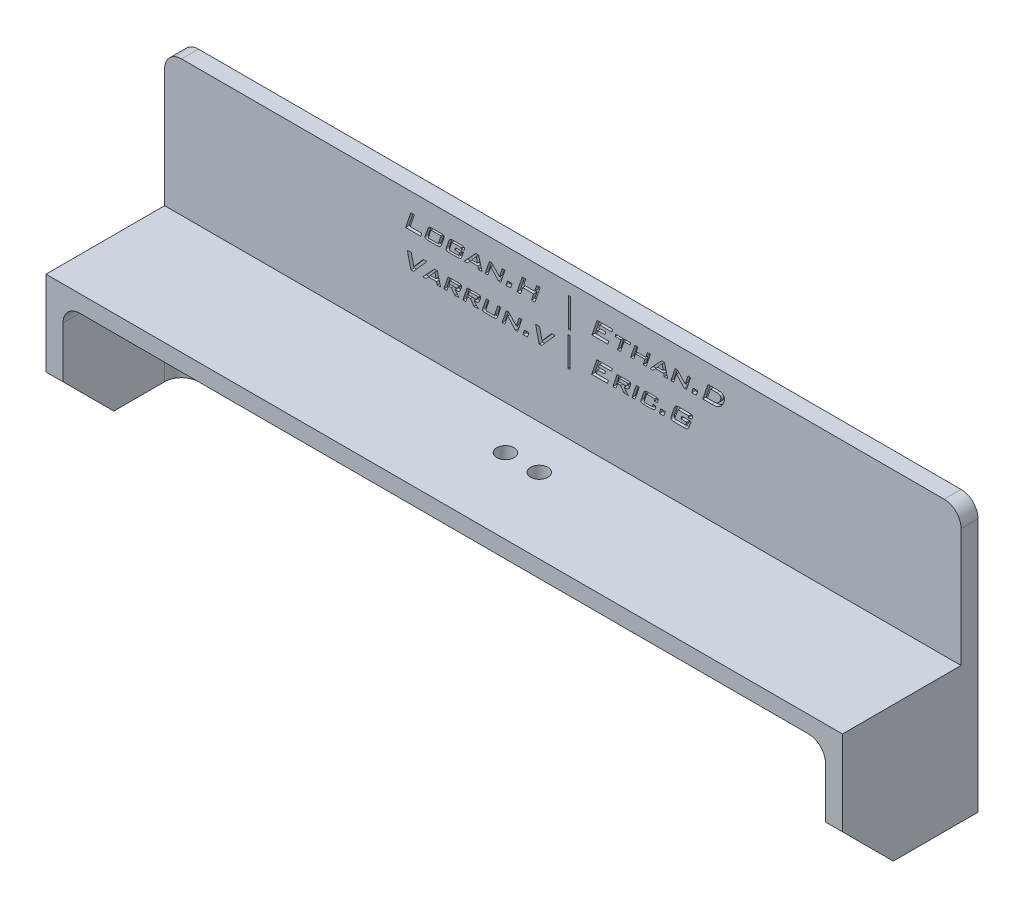
from build123d import *

# Parameters (mm, degrees)
SKETCH1_W                  = 235
SKETCH1_H                  = 40
BOSS_EXTRUDE1_DEPTH        = 5
BOSS_EXTRUDE2_DEPTH        = 35
M4_CLEARANCE_HOLE1_D       = 4.5
F_5_1_5_1_DIAMETER_HOLE1_D = 5.1
SKETCH7_W                  = 235
SKETCH7_H                  = 5
BOSS_EXTRUDE3_DEPTH        = 40
FILLET1_R                  = 5
FILLET2_R                  = 5
CHAMFER3_SIZE              = 15
SKETCH9_W                  = 0.642857143
SKETCH9_H                  = 8.678571428
CUT_EXTRUDE1_DEPTH         = 1


with BuildPart() as part:
    # Sketch1 → Boss-Extrude1 (new body)
    with BuildSketch(Plane(origin=(0, 0, 0), x_dir=(1, 0, 0), z_dir=(0, 1, 0))):
        with Locations((117.5, -20)):
            Rectangle(SKETCH1_W, SKETCH1_H)
    extrude(amount=BOSS_EXTRUDE1_DEPTH)

    # Sketch2 → Boss-Extrude2 (add)
    with BuildSketch(Plane.XZ):
        Polygon((5, 5), (230, 5), (230, 40), (235, 40), (235, 5), (235, 0), (0, 0), (0, 5), (0, 40), (5, 40), align=None)
    extrude(amount=BOSS_EXTRUDE2_DEPTH)

    # M4 Clearance Hole1 (through all)
    with Locations(Plane.XY.offset(5)):
        with Locations((117.5, -15), (55, -15), (180, -15)):
            Hole(M4_CLEARANCE_HOLE1_D / 2)

    # Ø5.1 (5.1) Diameter Hole1 (through all)
    with Locations(Plane.XZ):
        with Locations((113.391, 17.85), (123.391, 17.85)):
            Hole(F_5_1_5_1_DIAMETER_HOLE1_D / 2)

    # Sketch7 → Boss-Extrude3 (add)
    with BuildSketch(Plane(origin=(0, 5, 0), x_dir=(1, 0, 0), z_dir=(0, 1, 0))):
        with Locations((117.5, -2.5)):
            Rectangle(SKETCH7_W, SKETCH7_H)
    extrude(amount=BOSS_EXTRUDE3_DEPTH)

    # Fillet1
    fillet1_edges = [part.edges().sort_by_distance(p)[0] for p in [
        (0, 45, 2.5),
        (235, 45, 2.5),
    ]]
    fillet(fillet1_edges, radius=FILLET1_R)

    # Fillet2
    fillet2_edges = [part.edges().sort_by_distance(p)[0] for p in [
        (230, 0, 22.5),
        (117.5, 0, 5),
        (230, -17.5, 5),
        (5, 0, 22.5),
        (5, -17.5, 5),
    ]]
    fillet(fillet2_edges, radius=FILLET2_R)

    # Chamfer3
    chamfer3_edges = [part.edges().sort_by_distance(p)[0] for p in [
        (232.5, -35, 40),
        (2.5, -35, 40),
    ]]
    chamfer(chamfer3_edges, length=CHAMFER3_SIZE)

    # Sketch9 → Cut-Extrude1 (cut)
    with BuildSketch(Plane.XY.offset(5)):
        Polygon((71.125, 35), (72.654296875, 39.5), (73.698939732, 39.5), (72.469726562, 35.883928571), (75.844726562, 35.883928571), (75.544642857, 35), align=None)
        with BuildLine():
            add(Edge.make_bspline(
                [(77.638950893, 37.852678571), (77.652843693, 37.891726297), (77.679817038, 37.967538787), (77.72456726, 38.075690012), (77.773562323, 38.173690022), (77.825082294, 38.261551621), (77.877944121, 38.340613816), (77.934150178, 38.410130199), (77.994539771, 38.468823856), (78.057493144, 38.519770312), (78.127327402, 38.561940134), (78.205728066, 38.598178419), (78.293519811, 38.629407063), (78.390615477, 38.654334977), (78.496896448, 38.67278537), (78.612587279, 38.686300786), (78.737856395, 38.695453226), (78.824619995, 38.696096449), (78.869419643, 38.696428571)],
                knots=[0, 0, 0, 0, 1.211996894, 2.353133315, 3.420533607, 4.413475086, 5.330079007, 6.199887005, 7.022149298, 7.788683438, 8.56328607, 9.401070926, 10.310866562, 11.284611595, 12.329026891, 13.46311777, 14.690102424, 16, 16, 16, 16], degree=3))
            Line((78.869419643, 38.696428571), (81.724609375, 38.696428571))
            add(Edge.make_bspline(
                [(81.724609375, 38.696428571), (81.768990847, 38.696115098), (81.853666402, 38.695517021), (81.973947108, 38.68652516), (82.080900452, 38.673087941), (82.174437617, 38.655046561), (82.25465943, 38.630122681), (82.321624532, 38.599127901), (82.375786105, 38.562842011), (82.41705441, 38.519767307), (82.445443281, 38.468158944), (82.463890142, 38.407971594), (82.473770109, 38.338516973), (82.472659468, 38.259677669), (82.463903979, 38.171365386), (82.444015703, 38.07341286), (82.416648313, 37.965615836), (82.392603237, 37.891472175), (82.380022321, 37.852678571)],
                knots=[0, 0, 0, 0, 1.498290335, 2.858592954, 4.069855488, 5.136914266, 6.071036792, 6.899194346, 7.620495598, 8.260362657, 8.893167816, 9.59039307, 10.375848916, 11.252051464, 12.246246406, 13.368763817, 14.623279027, 16, 16, 16, 16], degree=3))
            Line((82.380022321, 37.852678571), (81.688197545, 35.816127232))
            add(Edge.make_bspline(
                [(81.688197545, 35.816127232), (81.674902283, 35.77825606), (81.649059092, 35.704642467), (81.602988061, 35.600991696), (81.557551755, 35.504888637), (81.507297639, 35.419063072), (81.452915722, 35.34346922), (81.396393757, 35.276541168), (81.33762425, 35.218311016), (81.274530358, 35.169216928), (81.205367066, 35.128242833), (81.127321303, 35.094853095), (81.04081965, 35.064105458), (80.94384335, 35.041346708), (80.838318999, 35.021958369), (80.72324171, 35.010633217), (80.598938459, 35.000799644), (80.512579697, 35.00027316), (80.467773438, 35)],
                knots=[0, 0, 0, 0, 1.192787368, 2.318527755, 3.370320139, 4.351986021, 5.270503255, 6.13563496, 6.953952691, 7.72552579, 8.506572516, 9.336631416, 10.245659931, 11.232516936, 12.294272195, 13.43341147, 14.668354776, 16, 16, 16, 16], degree=3))
            Line((80.467773438, 35), (77.612583705, 35))
            add(Edge.make_bspline(
                [(77.612583705, 35), (77.568193291, 35.000241658), (77.483918259, 35.000700444), (77.364217566, 35.010529767), (77.257403329, 35.021556735), (77.164284311, 35.040625952), (77.083759306, 35.063564545), (77.017173142, 35.094191604), (76.961277348, 35.127124349), (76.919057823, 35.169032123), (76.889291003, 35.219272489), (76.86927892, 35.277765321), (76.860052279, 35.345376315), (76.859279725, 35.421612679), (76.867019311, 35.507453829), (76.885431053, 35.602534027), (76.911774226, 35.706950079), (76.93497076, 35.778587876), (76.947126116, 35.816127232)],
                knots=[0, 0, 0, 0, 1.521997284, 2.88950602, 4.118173989, 5.202116483, 6.146774621, 6.982012263, 7.710919359, 8.360593675, 8.998261149, 9.697439647, 10.466921771, 11.328395985, 12.30839058, 13.417796864, 14.646884101, 16, 16, 16, 16], degree=3))
            Line((76.947126116, 35.816127232), (77.638950893, 37.852678571))
        make_face()
        Polygon((77.772042411, 35.642857143), (80.745256696, 35.642857143), (81.56515067, 38.053571429), (78.591936384, 38.053571429), align=None, mode=Mode.SUBTRACT)
        with BuildLine():
            Line((87.591936384, 38.053571429), (84.779436384, 38.053571429))
            Line((84.779436384, 38.053571429), (83.959542411, 35.642857143))
            Line((83.959542411, 35.642857143), (86.772042411, 35.642857143))
            Line((86.772042411, 35.642857143), (87.072126116, 36.526785714))
            Line((87.072126116, 36.526785714), (85.625697545, 36.526785714))
            Line((85.625697545, 36.526785714), (85.844168527, 37.169642857))
            Line((85.844168527, 37.169642857), (88.17452567, 37.169642857))
            Line((88.17452567, 37.169642857), (87.72000558, 35.829938616))
            add(Edge.make_bspline(
                [(87.72000558, 35.829938616), (87.70609848, 35.791317402), (87.679102745, 35.716347924), (87.634565126, 35.60930923), (87.584933489, 35.513210948), (87.53575385, 35.42481144), (87.479391935, 35.349081707), (87.423721995, 35.279822592), (87.362593965, 35.22226782), (87.299254733, 35.1714795), (87.227703156, 35.130775275), (87.148442678, 35.096078666), (87.060033073, 35.065346189), (86.961693272, 35.04298621), (86.854806742, 35.021386485), (86.737438573, 35.010807236), (86.611079471, 35.000787747), (86.523463284, 35.00026819), (86.478236607, 35)],
                knots=[0, 0, 0, 0, 1.199771225, 2.328933054, 3.384751006, 4.360355076, 5.280389326, 6.140230688, 6.953476884, 7.729148576, 8.507516255, 9.35084094, 10.256036939, 11.238061537, 12.296073877, 13.440242712, 14.678676631, 16, 16, 16, 16], degree=3))
            Line((86.478236607, 35), (83.801339286, 35))
            add(Edge.make_bspline(
                [(83.801339286, 35), (83.757365016, 35.000241356), (83.673503877, 35.000701633), (83.554670719, 35.010600914), (83.448069593, 35.021146768), (83.355340377, 35.042432794), (83.274174828, 35.064602107), (83.206733307, 35.095199024), (83.151691722, 35.12979122), (83.108583624, 35.171623149), (83.079684705, 35.222862286), (83.059036943, 35.281870538), (83.050136509, 35.350430485), (83.049255152, 35.427882255), (83.057075593, 35.514970845), (83.075292345, 35.611872802), (83.103158793, 35.718238512), (83.127109939, 35.791556449), (83.139648437, 35.829938616)],
                knots=[0, 0, 0, 0, 1.495661433, 2.852301421, 4.057061013, 5.13530816, 6.086102403, 6.914701705, 7.645488442, 8.289999247, 8.934824678, 9.628446215, 10.405897809, 11.274765026, 12.261158263, 13.375756298, 14.626200306, 16, 16, 16, 16], degree=3))
            Line((83.139648437, 35.829938616), (83.828962054, 37.858956473))
            add(Edge.make_bspline(
                [(83.828962054, 37.858956473), (83.842783098, 37.898034452), (83.869488487, 37.973541963), (83.91481364, 38.080421248), (83.962555828, 38.177928894), (84.013258167, 38.26559921), (84.068494838, 38.342882936), (84.123694279, 38.412231362), (84.183870359, 38.470837933), (84.247562431, 38.521051955), (84.318378515, 38.562818055), (84.39639228, 38.59951813), (84.484156461, 38.629234073), (84.580982284, 38.654597574), (84.687374724, 38.672508591), (84.802584334, 38.686361186), (84.927031278, 38.695468369), (85.013376163, 38.696100564), (85.058175223, 38.696428571)],
                knots=[0, 0, 0, 0, 1.216249724, 2.350070051, 3.404750931, 4.401176587, 5.317875156, 6.190735263, 6.998513246, 7.777385068, 8.565212501, 9.405937098, 10.303257531, 11.280419382, 12.340593243, 13.466468551, 14.685506066, 16, 16, 16, 16], degree=3))
            Line((85.058175223, 38.696428571), (87.735072545, 38.696428571))
            add(Edge.make_bspline(
                [(87.735072545, 38.696428571), (87.779459094, 38.696162412), (87.864144336, 38.695654605), (87.984308718, 38.68605974), (88.091827867, 38.674529989), (88.186220651, 38.656439504), (88.266983203, 38.630767189), (88.336181363, 38.602815305), (88.392261922, 38.567889188), (88.435964355, 38.52596474), (88.468070654, 38.477034154), (88.489663528, 38.419596821), (88.501443127, 38.354192189), (88.505231695, 38.279909696), (88.498034827, 38.197466441), (88.482476377, 38.106487196), (88.45874347, 38.006871472), (88.43622772, 37.938735884), (88.424386161, 37.902901786)],
                knots=[0, 0, 0, 0, 1.538633694, 2.935564179, 4.177662279, 5.287680266, 6.260797657, 7.112615428, 7.869511995, 8.536628724, 9.196763069, 9.881331851, 10.649826925, 11.49269626, 12.453287694, 13.512624815, 14.691831257, 16, 16, 16, 16], degree=3))
            Line((88.424386161, 37.902901786), (88.390485491, 37.802455357))
            Line((88.390485491, 37.802455357), (87.455078125, 37.651785714))
            Line((87.455078125, 37.651785714), (87.591936384, 38.053571429))
        make_face()
        Polygon((88.401785714, 35), (91.825753348, 38.696428571), (92.680803571, 38.696428571), (93.625, 35), (92.625558036, 35), (92.439732143, 35.803571429), (90.023995536, 35.803571429), (89.290736607, 35), align=None)
        Polygon((90.622907366, 36.446428571), (92.296595982, 36.446428571), (91.976422991, 38.014648437), align=None, mode=Mode.SUBTRACT)
        Polygon((94.589285714, 35), (95.846121652, 38.696428571), (96.468889509, 38.696428571), (98.787946429, 36.241768973), (99.622907366, 38.696428571), (100.426478795, 38.696428571), (99.169642857, 35), (98.541852679, 35), (96.240373884, 37.492327009), (95.392857143, 35), align=None)
        with BuildLine():
            Line((102.156668527, 36.366071429), (102.316127232, 36.366071429))
            add(Edge.make_bspline(
                [(102.316127232, 36.366071429), (102.333773593, 36.36558506), (102.365870748, 36.3647004), (102.409023818, 36.352999686), (102.44050135, 36.330587759), (102.46008403, 36.297728672), (102.466706876, 36.253505047), (102.458837623, 36.196481207), (102.444646528, 36.12419479), (102.426536284, 36.072064605), (102.416573661, 36.043387277)],
                knots=[0, 0, 0, 0, 0.986434206, 1.794235757, 2.464259831, 3.095046867, 3.880807048, 4.915838775, 6.303372501, 8, 8, 8, 8], degree=3))
            Line((102.416573661, 36.043387277), (102.174246652, 35.327706473))
            add(Edge.make_bspline(
                [(102.174246652, 35.327706473), (102.162940997, 35.296170684), (102.142156658, 35.238195229), (102.107956962, 35.160830202), (102.071910107, 35.102356516), (102.0329686, 35.057336394), (101.977720301, 35.028748445), (101.903506997, 35.012295774), (101.806255979, 35.001502909), (101.733576898, 35.000535386), (101.693359375, 35)],
                knots=[0, 0, 0, 0, 1.229507015, 2.260328052, 3.095472383, 3.74742085, 4.41421465, 5.334288324, 6.524908153, 8, 8, 8, 8], degree=3))
            Line((101.693359375, 35), (100.907366071, 35))
            add(Edge.make_bspline(
                [(100.907366071, 35), (100.889614116, 35.000203919), (100.857596412, 35.00057171), (100.815532725, 35.015319805), (100.7826463, 35.036303002), (100.763253597, 35.071000858), (100.758611923, 35.116424984), (100.765542934, 35.17419876), (100.780203075, 35.246900472), (100.798248343, 35.299029681), (100.808175223, 35.327706473)],
                knots=[0, 0, 0, 0, 0.978281508, 1.76444382, 2.447753433, 3.093285954, 3.891711503, 4.9413288, 6.317394815, 8, 8, 8, 8], degree=3))
            Line((100.808175223, 35.327706473), (101.050502232, 36.043387277))
            add(Edge.make_bspline(
                [(101.050502232, 36.043387277), (101.061825609, 36.074081049), (101.082738223, 36.130767938), (101.116857288, 36.206284522), (101.152010113, 36.263671388), (101.18945907, 36.30952518), (101.245667224, 36.336847036), (101.319885586, 36.353932427), (101.41727293, 36.3645131), (101.48992909, 36.3655163), (101.530133929, 36.366071429)],
                knots=[0, 0, 0, 0, 1.209966415, 2.234630208, 3.054834405, 3.701297643, 4.386778955, 5.313892331, 6.513621875, 8, 8, 8, 8], degree=3))
            Line((101.530133929, 36.366071429), (102.156668527, 36.366071429))
        make_face()
        Polygon((103.991071429, 35), (105.520368304, 39.5), (106.565011161, 39.5), (105.96484375, 37.732142857), (109.179129464, 37.732142857), (109.779296875, 39.5), (110.823939732, 39.5), (109.294642857, 35), (108.25, 35), (108.905412946, 36.928571429), (105.691127232, 36.928571429), (105.035714286, 35), align=None)
        with Locations((119.419642858, 37.330357143)):
            Rectangle(SKETCH9_W, SKETCH9_H)
        Polygon((126.089285714, 35), (127.618582589, 39.5), (132.198939732, 39.5), (131.926478795, 38.696428571), (128.390764509, 38.696428571), (128.089425223, 37.8125), (130.178710938, 37.8125), (129.90625, 37.008928571), (127.816964286, 37.008928571), (127.434012277, 35.883928571), (131.050083705, 35.883928571), (130.75, 35), align=None)
        Polygon((135.56515067, 38.053571429), (134.526785714, 35), (133.642857143, 35), (134.681222098, 38.053571429), (132.913364955, 38.053571429), (133.131835938, 38.696428571), (137.551478795, 38.696428571), (137.333007813, 38.053571429), align=None)
        Polygon((137.5, 35), (138.756835938, 38.696428571), (139.640764509, 38.696428571), (139.148577009, 37.25), (141.961077009, 37.25), (142.453264509, 38.696428571), (143.33719308, 38.696428571), (142.080357143, 35), (141.196428571, 35), (141.742606027, 36.607142857), (138.930106027, 36.607142857), (138.383928571, 35), align=None)
        Polygon((143.205357143, 35), (146.629324777, 38.696428571), (147.484375, 38.696428571), (148.428571429, 35), (147.429129464, 35), (147.243303571, 35.803571429), (144.827566964, 35.803571429), (144.094308036, 35), align=None)
        Polygon((145.426478795, 36.446428571), (147.100167411, 36.446428571), (146.77999442, 38.014648437), align=None, mode=Mode.SUBTRACT)
        Polygon((149.392857143, 35), (150.64969308, 38.696428571), (151.272460938, 38.696428571), (153.591517857, 36.241768973), (154.426478795, 38.696428571), (155.230050223, 38.696428571), (153.973214286, 35), (153.345424107, 35), (151.043945313, 37.492327009), (150.196428571, 35), align=None)
        with BuildLine():
            Line((156.960239955, 36.366071429), (157.119698661, 36.366071429))
            add(Edge.make_bspline(
                [(157.119698661, 36.366071429), (157.137345021, 36.36558506), (157.169442176, 36.3647004), (157.212595247, 36.352999686), (157.244072779, 36.330587759), (157.263655458, 36.297728672), (157.270278304, 36.253505047), (157.262409051, 36.196481207), (157.248217956, 36.12419479), (157.230107713, 36.072064605), (157.220145089, 36.043387277)],
                knots=[0, 0, 0, 0, 0.986434206, 1.794235757, 2.464259831, 3.095046867, 3.880807048, 4.915838775, 6.303372501, 8, 8, 8, 8], degree=3))
            Line((157.220145089, 36.043387277), (156.97781808, 35.327706473))
            add(Edge.make_bspline(
                [(156.97781808, 35.327706473), (156.966512425, 35.296170684), (156.945728087, 35.238195229), (156.91152839, 35.160830202), (156.875481536, 35.102356516), (156.836540029, 35.057336394), (156.781291729, 35.028748445), (156.707078425, 35.012295774), (156.609827408, 35.001502909), (156.537148326, 35.000535386), (156.496930804, 35)],
                knots=[0, 0, 0, 0, 1.229507015, 2.260328052, 3.095472383, 3.74742085, 4.41421465, 5.334288324, 6.524908153, 8, 8, 8, 8], degree=3))
            Line((156.496930804, 35), (155.7109375, 35))
            add(Edge.make_bspline(
                [(155.7109375, 35), (155.693185545, 35.000203919), (155.66116784, 35.00057171), (155.619104153, 35.015319805), (155.586217728, 35.036303002), (155.566825025, 35.071000858), (155.562183352, 35.116424984), (155.569114363, 35.17419876), (155.583774503, 35.246900472), (155.601819772, 35.299029681), (155.611746652, 35.327706473)],
                knots=[0, 0, 0, 0, 0.978281508, 1.76444382, 2.447753433, 3.093285954, 3.891711503, 4.9413288, 6.317394815, 8, 8, 8, 8], degree=3))
            Line((155.611746652, 35.327706473), (155.854073661, 36.043387277))
            add(Edge.make_bspline(
                [(155.854073661, 36.043387277), (155.865397038, 36.074081049), (155.886309652, 36.130767938), (155.920428716, 36.206284522), (155.955581542, 36.263671388), (155.993030498, 36.30952518), (156.049238653, 36.336847036), (156.123457015, 36.353932427), (156.220844358, 36.3645131), (156.293500518, 36.3655163), (156.333705357, 36.366071429)],
                knots=[0, 0, 0, 0, 1.209966415, 2.234630208, 3.054834405, 3.701297643, 4.386778955, 5.313892331, 6.513621875, 8, 8, 8, 8], degree=3))
            Line((156.333705357, 36.366071429), (156.960239955, 36.366071429))
        make_face()
        with BuildLine():
            Line((158.794642857, 35), (160.323939732, 39.5))
            Line((160.323939732, 39.5), (163.236886161, 39.5))
            add(Edge.make_bspline(
                [(163.236886161, 39.5), (163.335314428, 39.4985853), (163.524640666, 39.495864133), (163.797025731, 39.467633186), (164.04586435, 39.42358629), (164.271457643, 39.361548398), (164.472524547, 39.279819171), (164.650779457, 39.180742514), (164.804368456, 39.061663173), (164.933975411, 38.925143802), (165.038329167, 38.771185284), (165.116544366, 38.601518473), (165.168618368, 38.416376205), (165.192420484, 38.21670701), (165.192165836, 38.002131715), (165.163957746, 37.773074287), (165.112774968, 37.52826058), (165.059887264, 37.363407447), (165.032366071, 37.277622768)],
                knots=[0, 0, 0, 0, 1.323580647, 2.545900176, 3.678867731, 4.719749498, 5.686791039, 6.591782788, 7.454386378, 8.290704387, 9.113593677, 9.944817934, 10.793139051, 11.689739256, 12.641168872, 13.672583502, 14.788881504, 16, 16, 16, 16], degree=3))
            add(Edge.make_bspline(
                [(165.032366071, 37.277622768), (164.994189858, 37.174238507), (164.91831681, 36.968768181), (164.769154433, 36.676053805), (164.594367975, 36.399003406), (164.39367757, 36.139763825), (164.171531323, 35.901397377), (163.928404904, 35.690410336), (163.671162806, 35.500889182), (163.484686751, 35.399709596), (163.391322545, 35.349051339)],
                knots=[0, 0, 0, 0, 1.018589771, 2.024389116, 3.031736646, 4.04448419, 5.052300173, 6.039870673, 7.018609011, 8, 8, 8, 8], degree=3))
            add(Edge.make_bspline(
                [(163.391322545, 35.349051339), (163.330684441, 35.319518477), (163.207031846, 35.25929537), (163.008675478, 35.1875413), (162.797236009, 35.127141838), (162.569772906, 35.079491025), (162.322429323, 35.042867375), (162.050715663, 35.01939736), (161.752594289, 35.002039454), (161.54481164, 35.000699324), (161.436383929, 35)],
                knots=[0, 0, 0, 0, 0.807011251, 1.645649013, 2.521124076, 3.438019394, 4.425843287, 5.512774617, 6.702085289, 8, 8, 8, 8], degree=3))
            Line((161.436383929, 35), (158.794642857, 35))
        make_face()
        with BuildLine():
            Line((160.13936942, 35.883928571), (161.507952009, 35.883928571))
            add(Edge.make_bspline(
                [(161.507952009, 35.883928571), (161.596295108, 35.884666272), (161.767701931, 35.886097588), (162.016445691, 35.903560664), (162.249659773, 35.927364644), (162.465985295, 35.96366879), (162.66636434, 36.009627878), (162.849424305, 36.067744461), (163.017807376, 36.133375159), (163.170530307, 36.212113185), (163.309771653, 36.303562952), (163.43888041, 36.406958828), (163.557431776, 36.524462094), (163.665672716, 36.656147061), (163.764823266, 36.800657668), (163.854274672, 36.958574276), (163.933657897, 37.130080783), (163.977717131, 37.250906495), (164.000279018, 37.312779018)],
                knots=[0, 0, 0, 0, 1.359047786, 2.636879025, 3.835188901, 4.964823526, 6.009843081, 6.995620639, 7.917618667, 8.787448461, 9.634083769, 10.476889683, 11.32843363, 12.197500248, 13.095988922, 14.021757551, 14.9869801, 16, 16, 16, 16], degree=3))
            add(Edge.make_bspline(
                [(164.000279018, 37.312779018), (164.017846652, 37.367791308), (164.051481419, 37.473117135), (164.086818485, 37.628445186), (164.108154547, 37.773309558), (164.11205023, 37.908549583), (164.101508453, 38.033537158), (164.075047276, 38.148182478), (164.033750021, 38.253073249), (163.974704686, 38.346403472), (163.902687799, 38.431220884), (163.813331342, 38.502415908), (163.710045622, 38.563852507), (163.591064089, 38.611543103), (163.457964252, 38.651105289), (163.309748226, 38.677600506), (163.146449611, 38.694230445), (163.032690347, 38.695673899), (162.973214286, 38.696428571)],
                knots=[0, 0, 0, 0, 1.276221392, 2.443437126, 3.517763297, 4.508206351, 5.428015079, 6.283139801, 7.101009303, 7.907228623, 8.714137904, 9.549408629, 10.420601818, 11.362257409, 12.375263924, 13.485913234, 14.685575388, 16, 16, 16, 16], degree=3))
            Line((162.973214286, 38.696428571), (161.096121652, 38.696428571))
            Line((161.096121652, 38.696428571), (160.13936942, 35.883928571))
        make_face(mode=Mode.SUBTRACT)
        Polygon((72.675641741, 24.919642857), (71.609654018, 29.419642857), (72.803710938, 29.419642857), (73.515625, 26.166434152), (76.354492188, 29.419642857), (77.395368304, 29.419642857), (73.397600446, 24.919642857), align=None)
        Polygon((76.1875, 24.919642857), (79.611467634, 28.616071429), (80.466517857, 28.616071429), (81.410714286, 24.919642857), (80.411272321, 24.919642857), (80.225446429, 25.723214286), (77.809709821, 25.723214286), (77.076450893, 24.919642857), align=None)
        Polygon((78.408621652, 26.366071429), (80.082310268, 26.366071429), (79.762137277, 27.934291295), align=None, mode=Mode.SUBTRACT)
        with BuildLine():
            Line((82.375, 24.919642857), (83.631835938, 28.616071429))
            Line((83.631835938, 28.616071429), (86.98046875, 28.616071429))
            add(Edge.make_bspline(
                [(86.98046875, 28.616071429), (87.015216577, 28.615596859), (87.081871429, 28.614686517), (87.177608845, 28.607619801), (87.264050571, 28.593840568), (87.341073116, 28.575417929), (87.408538057, 28.551578874), (87.466814353, 28.522654812), (87.517027401, 28.489151991), (87.556450339, 28.447976708), (87.587682344, 28.401324168), (87.610128836, 28.348497927), (87.623666137, 28.289047348), (87.630397132, 28.22316299), (87.625171052, 28.150325778), (87.614184735, 28.070856043), (87.593445447, 27.985410096), (87.575128163, 27.927069314), (87.565569196, 27.896623884)],
                knots=[0, 0, 0, 0, 1.401274035, 2.687987182, 3.867269599, 4.927493221, 5.877766608, 6.745790689, 7.546380751, 8.298348459, 9.02859895, 9.799829426, 10.598103322, 11.479803043, 12.460031048, 13.534135329, 14.713176163, 16, 16, 16, 16], degree=3))
            Line((87.565569196, 27.896623884), (87.286830357, 27.076729911))
            add(Edge.make_bspline(
                [(87.286830357, 27.076729911), (87.264838853, 27.017282634), (87.22288658, 26.903877546), (87.132967722, 26.753666745), (87.029876296, 26.627634703), (86.907269459, 26.528128607), (86.764701249, 26.454363697), (86.60187063, 26.402016739), (86.416232801, 26.370708401), (86.285007426, 26.367672221), (86.215820312, 26.366071429)],
                knots=[0, 0, 0, 0, 1.088634214, 2.076742037, 2.997011214, 3.877709333, 4.773299467, 5.743502808, 6.810287044, 8, 8, 8, 8], degree=3))
            Line((86.215820312, 26.366071429), (85.703543527, 26.366071429))
            Line((85.703543527, 26.366071429), (86.935267857, 24.919642857))
            Line((86.935267857, 24.919642857), (85.647042411, 24.919642857))
            Line((85.647042411, 24.919642857), (84.597377232, 26.366071429))
            Line((84.597377232, 26.366071429), (83.751116071, 26.366071429))
            Line((83.751116071, 26.366071429), (83.258928571, 24.919642857))
            Line((83.258928571, 24.919642857), (82.375, 24.919642857))
        make_face()
        with BuildLine():
            Line((86.374023438, 27.973214286), (84.297293527, 27.973214286))
            Line((84.297293527, 27.973214286), (83.969587054, 27.008928571))
            Line((83.969587054, 27.008928571), (86.046316964, 27.008928571))
            add(Edge.make_bspline(
                [(86.046316964, 27.008928571), (86.083186776, 27.009436349), (86.152154509, 27.010386185), (86.247358999, 27.022606766), (86.326869185, 27.042253385), (86.392815392, 27.069799434), (86.446401448, 27.10980259), (86.491882222, 27.158931163), (86.529200132, 27.220178701), (86.546790233, 27.265981984), (86.556082589, 27.290178571)],
                knots=[0, 0, 0, 0, 1.396761691, 2.612746969, 3.628479476, 4.49501592, 5.300916421, 6.142855847, 7.01892289, 8, 8, 8, 8], degree=3))
            Line((86.556082589, 27.290178571), (86.691685268, 27.691964286))
            add(Edge.make_bspline(
                [(86.691685268, 27.691964286), (86.698982169, 27.715614112), (86.712109551, 27.758160981), (86.716556845, 27.819436192), (86.708255893, 27.871567961), (86.678759151, 27.913303075), (86.629697426, 27.941352042), (86.562695638, 27.959906313), (86.475308746, 27.972040525), (86.410065274, 27.972796609), (86.374023438, 27.973214286)],
                knots=[0, 0, 0, 0, 1.08649576, 1.95464402, 2.688528599, 3.363565505, 4.125616721, 5.128519845, 6.413735299, 8, 8, 8, 8], degree=3))
        make_face(mode=Mode.SUBTRACT)
        with BuildLine():
            Line((88, 24.919642857), (89.256835938, 28.616071429))
            Line((89.256835938, 28.616071429), (92.60546875, 28.616071429))
            add(Edge.make_bspline(
                [(92.60546875, 28.616071429), (92.640216577, 28.615596859), (92.706871429, 28.614686517), (92.802608845, 28.607619801), (92.889050571, 28.593840568), (92.966073116, 28.575417929), (93.033538057, 28.551578874), (93.091814353, 28.522654812), (93.142027401, 28.489151991), (93.181450339, 28.447976708), (93.212682344, 28.401324168), (93.235128836, 28.348497927), (93.248666137, 28.289047348), (93.255397132, 28.22316299), (93.250171052, 28.150325778), (93.239184735, 28.070856043), (93.218445447, 27.985410096), (93.200128163, 27.927069314), (93.190569196, 27.896623884)],
                knots=[0, 0, 0, 0, 1.401274035, 2.687987182, 3.867269599, 4.927493221, 5.877766608, 6.745790689, 7.546380751, 8.298348459, 9.02859895, 9.799829426, 10.598103322, 11.479803043, 12.460031048, 13.534135329, 14.713176163, 16, 16, 16, 16], degree=3))
            Line((93.190569196, 27.896623884), (92.911830357, 27.076729911))
            add(Edge.make_bspline(
                [(92.911830357, 27.076729911), (92.889838853, 27.017282634), (92.84788658, 26.903877546), (92.757967722, 26.753666745), (92.654876296, 26.627634703), (92.532269459, 26.528128607), (92.389701249, 26.454363697), (92.22687063, 26.402016739), (92.041232801, 26.370708401), (91.910007426, 26.367672221), (91.840820313, 26.366071429)],
                knots=[0, 0, 0, 0, 1.088634214, 2.076742037, 2.997011214, 3.877709333, 4.773299467, 5.743502808, 6.810287044, 8, 8, 8, 8], degree=3))
            Line((91.840820313, 26.366071429), (91.328543527, 26.366071429))
            Line((91.328543527, 26.366071429), (92.560267857, 24.919642857))
            Line((92.560267857, 24.919642857), (91.272042411, 24.919642857))
            Line((91.272042411, 24.919642857), (90.222377232, 26.366071429))
            Line((90.222377232, 26.366071429), (89.376116071, 26.366071429))
            Line((89.376116071, 26.366071429), (88.883928571, 24.919642857))
            Line((88.883928571, 24.919642857), (88, 24.919642857))
        make_face()
        with BuildLine():
            Line((91.999023438, 27.973214286), (89.922293527, 27.973214286))
            Line((89.922293527, 27.973214286), (89.594587054, 27.008928571))
            Line((89.594587054, 27.008928571), (91.671316964, 27.008928571))
            add(Edge.make_bspline(
                [(91.671316964, 27.008928571), (91.708186776, 27.009436349), (91.777154509, 27.010386185), (91.872358999, 27.022606766), (91.951869185, 27.042253385), (92.017815392, 27.069799434), (92.071401448, 27.10980259), (92.116882222, 27.158931163), (92.154200132, 27.220178701), (92.171790233, 27.265981984), (92.181082589, 27.290178571)],
                knots=[0, 0, 0, 0, 1.396761691, 2.612746969, 3.628479476, 4.49501592, 5.300916421, 6.142855847, 7.01892289, 8, 8, 8, 8], degree=3))
            Line((92.181082589, 27.290178571), (92.316685268, 27.691964286))
            add(Edge.make_bspline(
                [(92.316685268, 27.691964286), (92.323982169, 27.715614112), (92.337109551, 27.758160981), (92.341556845, 27.819436192), (92.333255893, 27.871567961), (92.303759151, 27.913303075), (92.254697426, 27.941352042), (92.187695638, 27.959906313), (92.100308746, 27.972040525), (92.035065274, 27.972796609), (91.999023438, 27.973214286)],
                knots=[0, 0, 0, 0, 1.08649576, 1.95464402, 2.688528599, 3.363565505, 4.125616721, 5.128519845, 6.413735299, 8, 8, 8, 8], degree=3))
        make_face(mode=Mode.SUBTRACT)
        with BuildLine():
            Line((95.765764509, 28.616071429), (94.727399554, 25.5625))
            Line((94.727399554, 25.5625), (97.298828125, 25.5625))
            Line((97.298828125, 25.5625), (98.33719308, 28.616071429))
            Line((98.33719308, 28.616071429), (99.221121652, 28.616071429))
            Line((99.221121652, 28.616071429), (98.246791295, 25.749581473))
            add(Edge.make_bspline(
                [(98.246791295, 25.749581473), (98.232932577, 25.711351602), (98.206036149, 25.637156645), (98.160933008, 25.531881999), (98.113336826, 25.435508903), (98.061674136, 25.348922494), (98.008071579, 25.270914611), (97.95160862, 25.202096573), (97.890721488, 25.144315077), (97.826936477, 25.09380211), (97.75641245, 25.05177204), (97.677435152, 25.016621547), (97.589470278, 24.986963928), (97.492647265, 24.961638286), (97.386325362, 24.943310552), (97.271059824, 24.929833291), (97.146632196, 24.920606767), (97.060704015, 24.91997115), (97.016322545, 24.919642857)],
                knots=[0, 0, 0, 0, 1.197113192, 2.323307898, 3.370404711, 4.359478287, 5.289276765, 6.155491697, 6.974766076, 7.756187431, 8.546593712, 9.384923531, 10.296829291, 11.27718975, 12.328700591, 13.470496253, 14.693524125, 16, 16, 16, 16], degree=3))
            Line((97.016322545, 24.919642857), (94.57296317, 24.919642857))
            add(Edge.make_bspline(
                [(94.57296317, 24.919642857), (94.528570254, 24.919874528), (94.444290475, 24.920314355), (94.325035828, 24.930236092), (94.218447774, 24.940812179), (94.12567762, 24.962005004), (94.044270352, 24.984564733), (93.976113989, 25.014505722), (93.920810343, 25.049461893), (93.877715835, 25.091262538), (93.848710322, 25.142492286), (93.828503109, 25.201638355), (93.817570962, 25.26992111), (93.816902697, 25.347622288), (93.826573374, 25.434538047), (93.844605347, 25.531339532), (93.8706362, 25.638088871), (93.894825521, 25.711237114), (93.90750558, 25.749581473)],
                knots=[0, 0, 0, 0, 1.507329636, 2.861659545, 4.06436768, 5.140778793, 6.08995403, 6.930114415, 7.659656772, 8.303070108, 8.946797534, 9.639237976, 10.417576369, 11.284964084, 12.271011094, 13.383711198, 14.628539604, 16, 16, 16, 16], degree=3))
            Line((93.90750558, 25.749581473), (94.881835938, 28.616071429))
            Line((94.881835938, 28.616071429), (95.765764509, 28.616071429))
        make_face()
        Polygon((99.571428571, 24.919642857), (100.828264509, 28.616071429), (101.451032366, 28.616071429), (103.770089286, 26.16141183), (104.605050223, 28.616071429), (105.408621652, 28.616071429), (104.151785714, 24.919642857), (103.523995536, 24.919642857), (101.222516741, 27.411969866), (100.375, 24.919642857), align=None)
        with BuildLine():
            Line((107.138811384, 26.285714286), (107.298270089, 26.285714286))
            add(Edge.make_bspline(
                [(107.298270089, 26.285714286), (107.31591645, 26.285227918), (107.348013605, 26.284343257), (107.391166676, 26.272642543), (107.422644207, 26.250230616), (107.442226887, 26.217371529), (107.448849733, 26.173147904), (107.44098048, 26.116124064), (107.426789385, 26.043837647), (107.408679141, 25.991707463), (107.398716518, 25.963030134)],
                knots=[0, 0, 0, 0, 0.986434206, 1.794235757, 2.464259831, 3.095046867, 3.880807048, 4.915838775, 6.303372501, 8, 8, 8, 8], degree=3))
            Line((107.398716518, 25.963030134), (107.156389509, 25.24734933))
            add(Edge.make_bspline(
                [(107.156389509, 25.24734933), (107.145083854, 25.215813541), (107.124299516, 25.157838086), (107.090099819, 25.080473059), (107.054052965, 25.021999373), (107.015111458, 24.976979252), (106.959863158, 24.948391302), (106.885649854, 24.931938631), (106.788398836, 24.921145766), (106.715719755, 24.920178243), (106.675502232, 24.919642857)],
                knots=[0, 0, 0, 0, 1.229507015, 2.260328052, 3.095472383, 3.74742085, 4.41421465, 5.334288324, 6.524908153, 8, 8, 8, 8], degree=3))
            Line((106.675502232, 24.919642857), (105.889508929, 24.919642857))
            add(Edge.make_bspline(
                [(105.889508929, 24.919642857), (105.871756973, 24.919846776), (105.839739269, 24.920214567), (105.797675582, 24.934962662), (105.764789157, 24.95594586), (105.745396454, 24.990643715), (105.74075478, 25.036067841), (105.747685791, 25.093841617), (105.762345932, 25.16654333), (105.7803912, 25.218672539), (105.79031808, 25.24734933)],
                knots=[0, 0, 0, 0, 0.978281508, 1.76444382, 2.447753433, 3.093285954, 3.891711503, 4.9413288, 6.317394815, 8, 8, 8, 8], degree=3))
            Line((105.79031808, 25.24734933), (106.032645089, 25.963030134))
            add(Edge.make_bspline(
                [(106.032645089, 25.963030134), (106.043968466, 25.993723906), (106.06488108, 26.050410795), (106.099000145, 26.125927379), (106.13415297, 26.183314245), (106.171601927, 26.229168037), (106.227810081, 26.256489893), (106.302028444, 26.273575284), (106.399415787, 26.284155957), (106.472071947, 26.285159157), (106.512276786, 26.285714286)],
                knots=[0, 0, 0, 0, 1.209966415, 2.234630208, 3.054834405, 3.701297643, 4.386778955, 5.313892331, 6.513621875, 8, 8, 8, 8], degree=3))
            Line((106.512276786, 26.285714286), (107.138811384, 26.285714286))
        make_face()
        Polygon((110.523856027, 24.919642857), (109.457868304, 29.419642857), (110.651925223, 29.419642857), (111.363839286, 26.166434152), (114.202706473, 29.419642857), (115.243582589, 29.419642857), (111.245814732, 24.919642857), align=None)
        with Locations((119.339285714, 27.25)):
            Rectangle(SKETCH9_W, SKETCH9_H)
        Polygon((126.008928571, 24.919642857), (127.538225446, 29.419642857), (132.118582589, 29.419642857), (131.846121652, 28.616071429), (128.310407366, 28.616071429), (128.00906808, 27.732142857), (130.098353795, 27.732142857), (129.825892857, 26.928571429), (127.736607143, 26.928571429), (127.353655134, 25.803571429), (130.969726563, 25.803571429), (130.669642857, 24.919642857), align=None)
        with BuildLine():
            Line((132.276785714, 24.919642857), (133.533621652, 28.616071429))
            Line((133.533621652, 28.616071429), (136.882254464, 28.616071429))
            add(Edge.make_bspline(
                [(136.882254464, 28.616071429), (136.917002291, 28.615596859), (136.983657143, 28.614686517), (137.079394559, 28.607619801), (137.165836286, 28.593840568), (137.242858831, 28.575417929), (137.310323771, 28.551578874), (137.368600067, 28.522654812), (137.418813116, 28.489151991), (137.458236053, 28.447976708), (137.489468058, 28.401324168), (137.511914551, 28.348497927), (137.525451851, 28.289047348), (137.532182847, 28.22316299), (137.526956766, 28.150325778), (137.515970449, 28.070856043), (137.495231162, 27.985410096), (137.476913877, 27.927069314), (137.467354911, 27.896623884)],
                knots=[0, 0, 0, 0, 1.401274035, 2.687987182, 3.867269599, 4.927493221, 5.877766608, 6.745790689, 7.546380751, 8.298348459, 9.02859895, 9.799829426, 10.598103322, 11.479803043, 12.460031048, 13.534135329, 14.713176163, 16, 16, 16, 16], degree=3))
            Line((137.467354911, 27.896623884), (137.188616071, 27.076729911))
            add(Edge.make_bspline(
                [(137.188616071, 27.076729911), (137.166624568, 27.017282634), (137.124672294, 26.903877546), (137.034753437, 26.753666745), (136.931662011, 26.627634703), (136.809055174, 26.528128607), (136.666486963, 26.454363697), (136.503656344, 26.402016739), (136.318018515, 26.370708401), (136.186793141, 26.367672221), (136.117606027, 26.366071429)],
                knots=[0, 0, 0, 0, 1.088634214, 2.076742037, 2.997011214, 3.877709333, 4.773299467, 5.743502808, 6.810287044, 8, 8, 8, 8], degree=3))
            Line((136.117606027, 26.366071429), (135.605329241, 26.366071429))
            Line((135.605329241, 26.366071429), (136.837053571, 24.919642857))
            Line((136.837053571, 24.919642857), (135.548828125, 24.919642857))
            Line((135.548828125, 24.919642857), (134.499162946, 26.366071429))
            Line((134.499162946, 26.366071429), (133.652901786, 26.366071429))
            Line((133.652901786, 26.366071429), (133.160714286, 24.919642857))
            Line((133.160714286, 24.919642857), (132.276785714, 24.919642857))
        make_face()
        with BuildLine():
            Line((136.275809152, 27.973214286), (134.199079241, 27.973214286))
            Line((134.199079241, 27.973214286), (133.871372768, 27.008928571))
            Line((133.871372768, 27.008928571), (135.948102679, 27.008928571))
            add(Edge.make_bspline(
                [(135.948102679, 27.008928571), (135.98497249, 27.009436349), (136.053940223, 27.010386185), (136.149144714, 27.022606766), (136.228654899, 27.042253385), (136.294601106, 27.069799434), (136.348187162, 27.10980259), (136.393667936, 27.158931163), (136.430985846, 27.220178701), (136.448575947, 27.265981984), (136.457868304, 27.290178571)],
                knots=[0, 0, 0, 0, 1.396761691, 2.612746969, 3.628479476, 4.49501592, 5.300916421, 6.142855847, 7.01892289, 8, 8, 8, 8], degree=3))
            Line((136.457868304, 27.290178571), (136.593470982, 27.691964286))
            add(Edge.make_bspline(
                [(136.593470982, 27.691964286), (136.600767884, 27.715614112), (136.613895265, 27.758160981), (136.61834256, 27.819436192), (136.610041608, 27.871567961), (136.580544866, 27.913303075), (136.53148314, 27.941352042), (136.464481352, 27.959906313), (136.377094461, 27.972040525), (136.311850988, 27.972796609), (136.275809152, 27.973214286)],
                knots=[0, 0, 0, 0, 1.08649576, 1.95464402, 2.688528599, 3.363565505, 4.125616721, 5.128519845, 6.413735299, 8, 8, 8, 8], degree=3))
        make_face(mode=Mode.SUBTRACT)
        Polygon((137.901785714, 24.919642857), (139.158621652, 28.616071429), (140.042550223, 28.616071429), (138.785714286, 24.919642857), align=None)
        with BuildLine():
            Line((144.725864955, 27.973214286), (142.234793527, 27.973214286))
            Line((142.234793527, 27.973214286), (141.414899554, 25.5625))
            Line((141.414899554, 25.5625), (143.905970982, 25.5625))
            Line((143.905970982, 25.5625), (144.1796875, 26.366071429))
            Line((144.1796875, 26.366071429), (144.999581473, 26.177734375))
            Line((144.999581473, 26.177734375), (144.84765625, 25.733258929))
            add(Edge.make_bspline(
                [(144.84765625, 25.733258929), (144.834241562, 25.695441189), (144.808350089, 25.62244978), (144.76424471, 25.518732233), (144.716844331, 25.424759658), (144.666298501, 25.340150387), (144.613789126, 25.263949839), (144.556986728, 25.197550983), (144.498282398, 25.138761774), (144.43412731, 25.090436358), (144.364270044, 25.049114742), (144.286406149, 25.014061104), (144.198515986, 24.985842741), (144.102319999, 24.960385821), (143.996470864, 24.941786259), (143.881460195, 24.930220627), (143.757137252, 24.920458138), (143.670781343, 24.919921359), (143.625976562, 24.919642857)],
                knots=[0, 0, 0, 0, 1.193869474, 2.30426824, 3.351400918, 4.323243018, 5.235394791, 6.101311351, 6.920371466, 7.702523493, 8.48427879, 9.331544045, 10.237382092, 11.228191838, 12.29091033, 13.431083041, 14.667146698, 16, 16, 16, 16], degree=3))
            Line((143.625976562, 24.919642857), (141.257952009, 24.919642857))
            add(Edge.make_bspline(
                [(141.257952009, 24.919642857), (141.214399396, 24.919907105), (141.130962666, 24.920413343), (141.012512073, 24.930118636), (140.906516653, 24.941133975), (140.813908923, 24.960603496), (140.732978178, 24.983277474), (140.665265873, 25.013455895), (140.609105481, 25.047167582), (140.565720141, 25.088536288), (140.534970605, 25.138496805), (140.513178194, 25.196346658), (140.502591617, 25.263670626), (140.502176506, 25.340019829), (140.510104167, 25.42529921), (140.526736682, 25.520214018), (140.553497347, 25.624059177), (140.576614119, 25.695711803), (140.588727679, 25.733258929)],
                knots=[0, 0, 0, 0, 1.496600396, 2.867140073, 4.084243237, 5.156491035, 6.117026805, 6.96724294, 7.697765584, 8.35913175, 9.005779707, 9.697887761, 10.471353616, 11.334737199, 12.31690385, 13.412073679, 14.643885061, 16, 16, 16, 16], degree=3))
            Line((140.588727679, 25.733258929), (141.280552455, 27.769810268))
            add(Edge.make_bspline(
                [(141.280552455, 27.769810268), (141.294270761, 27.809347892), (141.320837502, 27.88591608), (141.367721537, 27.99377711), (141.416356639, 28.092096922), (141.468161039, 28.18049427), (141.521777915, 28.259749156), (141.578281923, 28.329737958), (141.638745186, 28.388871086), (141.702932017, 28.439412445), (141.773700443, 28.481303909), (141.852017876, 28.517559348), (141.93957527, 28.54953295), (142.036889375, 28.573729337), (142.143505116, 28.592486984), (142.258802314, 28.605856559), (142.383638394, 28.615144103), (142.469986971, 28.615754652), (142.514787946, 28.616071429)],
                knots=[0, 0, 0, 0, 1.220334783, 2.363288746, 3.427927784, 4.418300626, 5.349493483, 6.217051379, 7.037186564, 7.811327109, 8.594368865, 9.429986458, 10.325940952, 11.308987948, 12.350701449, 13.481858553, 14.693490994, 16, 16, 16, 16], degree=3))
            Line((142.514787946, 28.616071429), (144.8828125, 28.616071429))
            add(Edge.make_bspline(
                [(144.8828125, 28.616071429), (144.92719494, 28.615772993), (145.011454834, 28.615206413), (145.131308035, 28.606094557), (145.237846389, 28.592733413), (145.331391095, 28.574695513), (145.411588494, 28.549743673), (145.478629449, 28.518839275), (145.532798333, 28.482111966), (145.575119155, 28.439512902), (145.605139186, 28.388153128), (145.623262071, 28.327566418), (145.633282244, 28.257761776), (145.632219996, 28.178462072), (145.623003953, 28.089898654), (145.605175116, 27.991644111), (145.577263908, 27.883465054), (145.552511186, 27.809006325), (145.539481027, 27.769810268)],
                knots=[0, 0, 0, 0, 1.495299353, 2.838820101, 4.047664637, 5.112593285, 6.044851056, 6.87135539, 7.591216736, 8.239544676, 8.878134392, 9.573967802, 10.357855672, 11.246413177, 12.238623444, 13.356322314, 14.608333181, 16, 16, 16, 16], degree=3))
            Line((145.539481027, 27.769810268), (145.41141183, 27.390625))
            Line((145.41141183, 27.390625), (144.479771205, 27.25))
            Line((144.479771205, 27.25), (144.725864955, 27.973214286))
        make_face()
        with BuildLine():
            Line((147.397739955, 26.285714286), (147.557198661, 26.285714286))
            add(Edge.make_bspline(
                [(147.557198661, 26.285714286), (147.574845021, 26.285227918), (147.606942176, 26.284343257), (147.650095247, 26.272642543), (147.681572779, 26.250230616), (147.701155458, 26.217371529), (147.707778304, 26.173147904), (147.699909051, 26.116124064), (147.685717956, 26.043837647), (147.667607713, 25.991707463), (147.657645089, 25.963030134)],
                knots=[0, 0, 0, 0, 0.986434206, 1.794235757, 2.464259831, 3.095046867, 3.880807048, 4.915838775, 6.303372501, 8, 8, 8, 8], degree=3))
            Line((147.657645089, 25.963030134), (147.41531808, 25.24734933))
            add(Edge.make_bspline(
                [(147.41531808, 25.24734933), (147.404012425, 25.215813541), (147.383228087, 25.157838086), (147.34902839, 25.080473059), (147.312981536, 25.021999373), (147.274040029, 24.976979252), (147.218791729, 24.948391302), (147.144578425, 24.931938631), (147.047327408, 24.921145766), (146.974648326, 24.920178243), (146.934430804, 24.919642857)],
                knots=[0, 0, 0, 0, 1.229507015, 2.260328052, 3.095472383, 3.74742085, 4.41421465, 5.334288324, 6.524908153, 8, 8, 8, 8], degree=3))
            Line((146.934430804, 24.919642857), (146.1484375, 24.919642857))
            add(Edge.make_bspline(
                [(146.1484375, 24.919642857), (146.130685545, 24.919846776), (146.09866784, 24.920214567), (146.056604153, 24.934962662), (146.023717728, 24.95594586), (146.004325025, 24.990643715), (145.999683352, 25.036067841), (146.006614363, 25.093841617), (146.021274503, 25.16654333), (146.039319772, 25.218672539), (146.049246652, 25.24734933)],
                knots=[0, 0, 0, 0, 0.978281508, 1.76444382, 2.447753433, 3.093285954, 3.891711503, 4.9413288, 6.317394815, 8, 8, 8, 8], degree=3))
            Line((146.049246652, 25.24734933), (146.291573661, 25.963030134))
            add(Edge.make_bspline(
                [(146.291573661, 25.963030134), (146.302897038, 25.993723906), (146.323809652, 26.050410795), (146.357928716, 26.125927379), (146.393081542, 26.183314245), (146.430530498, 26.229168037), (146.486738653, 26.256489893), (146.560957015, 26.273575284), (146.658344358, 26.284155957), (146.731000518, 26.285159157), (146.771205357, 26.285714286)],
                knots=[0, 0, 0, 0, 1.209966415, 2.234630208, 3.054834405, 3.701297643, 4.386778955, 5.313892331, 6.513621875, 8, 8, 8, 8], degree=3))
            Line((146.771205357, 26.285714286), (147.397739955, 26.285714286))
        make_face()
        with BuildLine():
            Line((154.667550223, 28.616071429), (151.453264509, 28.616071429))
            Line((151.453264509, 28.616071429), (150.496512277, 25.803571429))
            Line((150.496512277, 25.803571429), (153.710797991, 25.803571429))
            Line((153.710797991, 25.803571429), (154.012137277, 26.6875))
            Line((154.012137277, 26.6875), (152.324637277, 26.6875))
            Line((152.324637277, 26.6875), (152.597098214, 27.491071429))
            Line((152.597098214, 27.491071429), (155.329241071, 27.491071429))
            Line((155.329241071, 27.491071429), (154.820731027, 25.995675223))
            add(Edge.make_bspline(
                [(154.820731027, 25.995675223), (154.803211369, 25.94569579), (154.769182792, 25.84862032), (154.712034431, 25.710778881), (154.64974374, 25.585968083), (154.586699977, 25.472925927), (154.5194657, 25.372622327), (154.449567724, 25.284191341), (154.375308971, 25.208629737), (154.297352424, 25.1441142), (154.211668519, 25.089901562), (154.116354979, 25.04402128), (154.009989088, 25.004894087), (153.892142861, 24.974007373), (153.763413216, 24.949040417), (153.623307855, 24.93170337), (153.472377701, 24.921964937), (153.368038912, 24.920434823), (153.314034598, 24.919642857)],
                knots=[0, 0, 0, 0, 1.248014044, 2.424028104, 3.513558415, 4.533877449, 5.472191233, 6.356377511, 7.186364155, 7.964318135, 8.735931102, 9.569660131, 10.452800523, 11.402655609, 12.437554073, 13.541058126, 14.727285695, 16, 16, 16, 16], degree=3))
            Line((153.314034598, 24.919642857), (150.26297433, 24.919642857))
            add(Edge.make_bspline(
                [(150.26297433, 24.919642857), (150.21105921, 24.920399368), (150.112564773, 24.921834636), (149.972495687, 24.931558584), (149.84806637, 24.948258277), (149.739037194, 24.973847442), (149.644706171, 25.003563675), (149.566111225, 25.042852711), (149.503433193, 25.08955896), (149.454269467, 25.143993254), (149.42063036, 25.209740032), (149.401876704, 25.286935559), (149.391424673, 25.375150456), (149.395936526, 25.475767641), (149.407664983, 25.588508662), (149.434909118, 25.713399278), (149.468785456, 25.851421582), (149.500528429, 25.946080405), (149.517159598, 25.995675223)],
                knots=[0, 0, 0, 0, 1.431489006, 2.715850487, 3.869766267, 4.888768609, 5.801156001, 6.590842969, 7.299457318, 7.945437901, 8.595836374, 9.312487487, 10.125608441, 11.037630805, 12.082702759, 13.248332555, 14.558312433, 16, 16, 16, 16], degree=3))
            Line((149.517159598, 25.995675223), (150.309430804, 28.324776786))
            add(Edge.make_bspline(
                [(150.309430804, 28.324776786), (150.32731162, 28.375623068), (150.361751015, 28.473555691), (150.420349246, 28.6123474), (150.479752822, 28.739598782), (150.543935098, 28.853911705), (150.61036884, 28.956039233), (150.679303369, 29.046225648), (150.75236105, 29.122941549), (150.829076084, 29.189288798), (150.914213386, 29.243617587), (151.007631384, 29.291928468), (151.112605658, 29.331789082), (151.228236483, 29.364033796), (151.35417933, 29.389048817), (151.490574678, 29.405948266), (151.637628595, 29.417784353), (151.739511078, 29.419008783), (151.792271205, 29.419642857)],
                knots=[0, 0, 0, 0, 1.276004388, 2.457651796, 3.565910236, 4.59975078, 5.55908292, 6.449161414, 7.28335938, 8.063782389, 8.844457065, 9.668884141, 10.550480488, 11.497965388, 12.508650501, 13.587948927, 14.750912654, 16, 16, 16, 16], degree=3))
            Line((151.792271205, 29.419642857), (154.843331473, 29.419642857))
            add(Edge.make_bspline(
                [(154.843331473, 29.419642857), (154.896078166, 29.41886368), (154.996234396, 29.417384166), (155.138459919, 29.407953189), (155.265171697, 29.39040557), (155.376565179, 29.366656707), (155.472230353, 29.333231866), (155.553600978, 29.29558976), (155.618997497, 29.24886767), (155.669524484, 29.193844614), (155.704932736, 29.129061533), (155.729102228, 29.054156189), (155.740668188, 28.968058795), (155.741872373, 28.870626022), (155.728783469, 28.762018923), (155.708283157, 28.641706418), (155.672806121, 28.510580485), (155.644313099, 28.420089992), (155.629324777, 28.372488839)],
                knots=[0, 0, 0, 0, 1.46511472, 2.78198234, 3.955779179, 5.016169568, 5.938916823, 6.765572207, 7.498014268, 8.156422423, 8.822584026, 9.532065665, 10.331040253, 11.226209943, 12.231385021, 13.364709013, 14.613745113, 16, 16, 16, 16], degree=3))
            Line((155.629324777, 28.372488839), (155.590401786, 28.258231027))
            Line((155.590401786, 28.258231027), (154.475446429, 28.053571429))
            Line((154.475446429, 28.053571429), (154.667550223, 28.616071429))
        make_face()
    extrude(amount=-CUT_EXTRUDE1_DEPTH, mode=Mode.SUBTRACT)


solid = part.part
